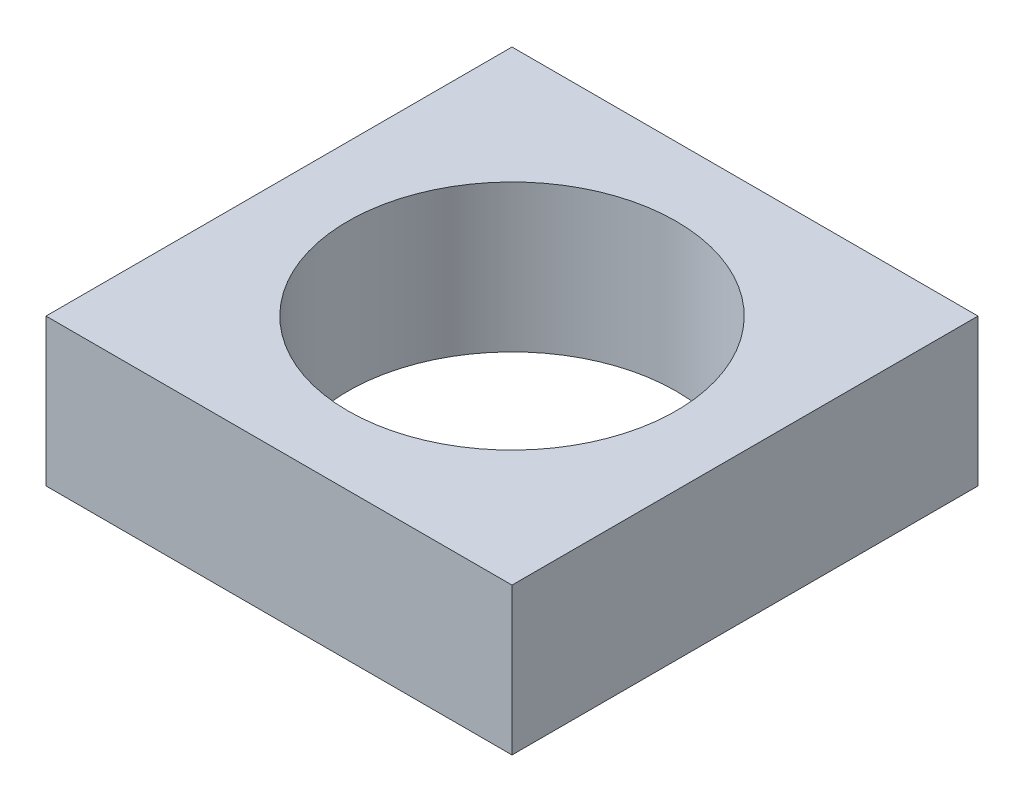
from build123d import *

# Parameters (mm, degrees)
SKETCH1_W           = 9.652
SKETCH1_H           = 9.652
SKETCH1_R           = 3.40106
BOSS_EXTRUDE1_DEPTH = 3.048


with BuildPart() as part:
    # Sketch1 → Boss-Extrude1 (new body)
    with BuildSketch(Plane(origin=(0, 0, 0), x_dir=(1, 0, 0), z_dir=(0, 1, 0))):
        Rectangle(SKETCH1_W, SKETCH1_H)
        Circle(SKETCH1_R, mode=Mode.SUBTRACT)
    extrude(amount=BOSS_EXTRUDE1_DEPTH)


solid = part.part
